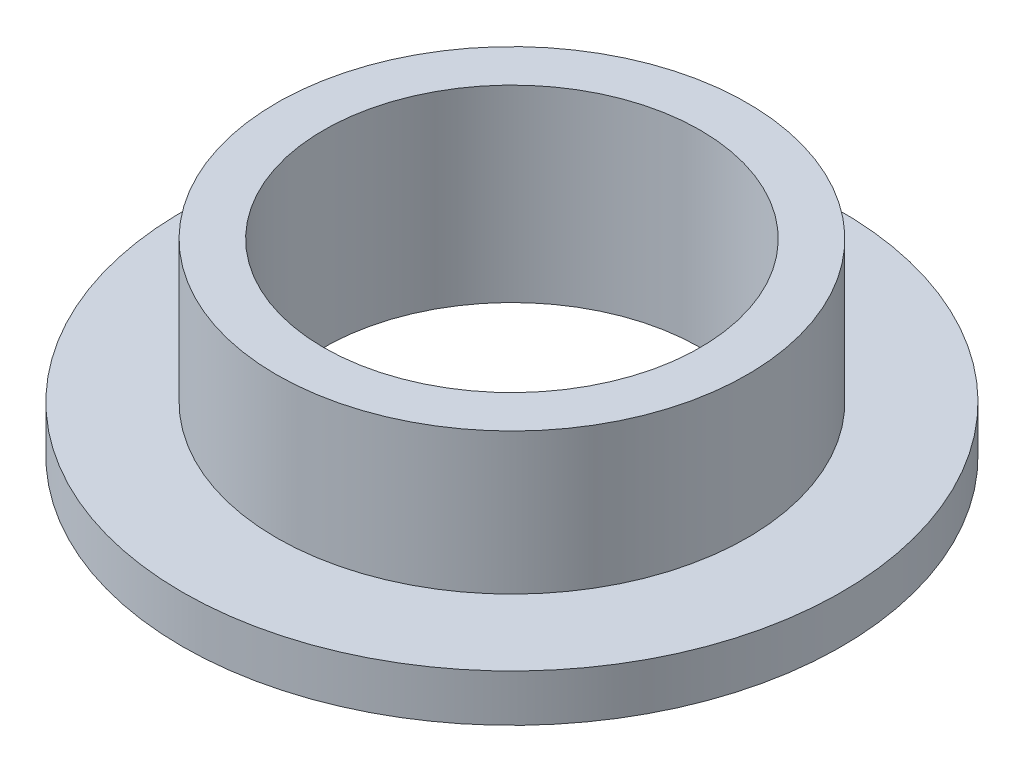
from build123d import *

# Parameters (mm, degrees)
SKETCH2_R           = 7.9375
SKETCH2_R_2         = 6.35
BOSS_EXTRUDE1_DEPTH = 6.35
SKETCH3_R           = 11.1125
SKETCH3_R_2         = 7.9375
BOSS_EXTRUDE2_DEPTH = 1.5875


with BuildPart() as part:
    # Sketch2 → Boss-Extrude1 (new body)
    with BuildSketch(Plane(origin=(0, 0, 0), x_dir=(1, 0, 0), z_dir=(0, 1, 0))):
        Circle(SKETCH2_R)
        Circle(SKETCH2_R_2, mode=Mode.SUBTRACT)
    extrude(amount=BOSS_EXTRUDE1_DEPTH)

    # Sketch3 → Boss-Extrude2 (add)
    with BuildSketch(Plane(origin=(0, 0, 0), x_dir=(1, 0, 0), z_dir=(0, 1, 0))):
        Circle(SKETCH3_R)
        Circle(SKETCH3_R_2, mode=Mode.SUBTRACT)
    extrude(amount=BOSS_EXTRUDE2_DEPTH)


solid = part.part
